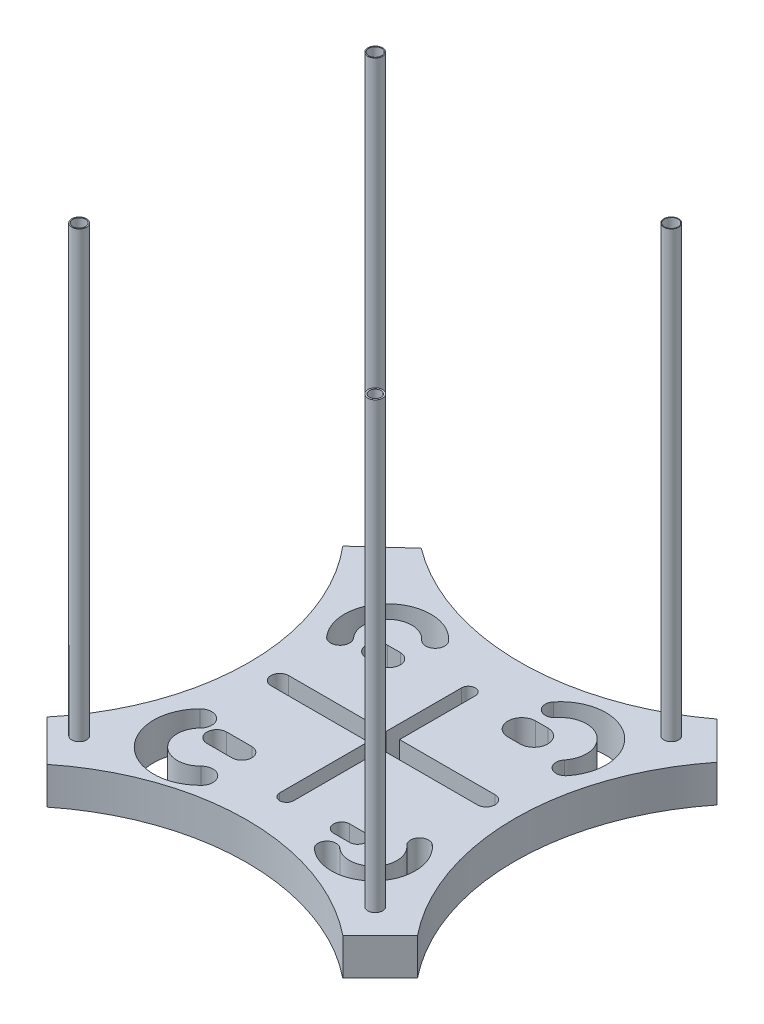
from build123d import *

# Parameters (mm, degrees)
BOSS_EXTRUDE1_DEPTH = 5
CUT_EXTRUDE1_DEPTH  = 15
CUT_EXTRUDE4_DEPTH  = 15
SKETCH7_R           = 1
BOSS_EXTRUDE2_DEPTH = 60
SKETCH8_R           = 0.873363885
CUT_EXTRUDE5_DEPTH  = 15
SKETCH9_R           = 0.918957051
CUT_EXTRUDE6_DEPTH  = 15
SKETCH10_R          = 0.859226697
CUT_EXTRUDE7_DEPTH  = 15
SKETCH11_R          = 0.786945752
CUT_EXTRUDE8_DEPTH  = 15


with BuildPart() as part:
    # Sketch1 → Boss-Extrude1 (new body)
    with BuildSketch(Plane(origin=(0, 0, 0), x_dir=(1, 0, 0), z_dir=(0, 1, 0))):
        with BuildLine():
            Line((-35.448928743, 52.732943935), (-27.948927155, 60.232942347))
            ThreePointArc((-27.948927155, 60.232942347), (-7.948927155, 52.732942347), (12.051072845, 60.232942347))
            Line((12.051072845, 60.232942347), (19.551072845, 52.732939171))
            ThreePointArc((19.551072845, 52.732939171), (12.051076647, 32.732945116), (19.551072845, 12.73295106))
            Line((19.551072845, 12.73295106), (12.051060957, 5.232942347))
            ThreePointArc((12.051060957, 5.232942347), (5.043506988, 9.818456658), (-2.948938922, 12.319169055))
            ThreePointArc((-2.948938922, 12.319169055), (-7.948938922, 12.848178709), (-12.948938922, 12.319169055))
            ThreePointArc((-12.948938922, 12.319169055), (-20.941384832, 9.818456658), (-27.9489388, 5.232942347))
            Line((-27.9489388, 5.232942347), (-35.448937212, 12.732943935))
            ThreePointArc((-35.448937212, 12.732943935), (-27.948932978, 32.732942347), (-35.448928743, 52.732943935))
        make_face()
    extrude(amount=BOSS_EXTRUDE1_DEPTH)

    # Sketch3 → Cut-Extrude1 (cut)
    with BuildSketch(Plane(origin=(0, 5, 0), x_dir=(1, 0, 0), z_dir=(0, 1, 0))):
        with BuildLine():
            Line((-27.948927155, 60.232942347), (-35.448928743, 52.732943935))
            ThreePointArc((-35.448928743, 52.732943935), (-27.948932978, 32.732942347), (-35.448937212, 12.732943935))
            Line((-35.448937212, 12.732943935), (-27.9489388, 5.232942347))
            ThreePointArc((-27.9489388, 5.232942347), (-7.948938922, 12.848178709), (12.051060957, 5.232942347))
            Line((12.051060957, 5.232942347), (19.551072845, 12.73295106))
            ThreePointArc((19.551072845, 12.73295106), (12.051076647, 32.732945116), (19.551072845, 52.732939171))
            Line((19.551072845, 52.732939171), (12.051072845, 60.232942347))
            ThreePointArc((12.051072845, 60.232942347), (-7.948927155, 52.732942347), (-27.948927155, 60.232942347))
        make_face()
        with BuildLine():
            Line((-33.493710626, 12.732943935), (-27.9489388, 7.18817211))
            ThreePointArc((-27.9489388, 7.18817211), (-7.948938922, 14.210022681), (12.051060957, 7.18817211))
            Line((12.051060957, 7.18817211), (17.099712422, 12.236821437))
            ThreePointArc((17.099712422, 12.236821437), (10.006359282, 32.484880304), (17.099712422, 52.732939171))
            Line((17.099712422, 52.732939171), (12.051072845, 57.781578748))
            ThreePointArc((12.051072845, 57.781578748), (-7.948927155, 51.108457819), (-27.948927155, 57.781578748))
            Line((-27.948927155, 57.781578748), (-33.493710626, 52.732943935))
            ThreePointArc((-33.493710626, 52.732943935), (-26.205843846, 32.732943935), (-33.493710626, 12.732943935))
        make_face(mode=Mode.SUBTRACT)
    extrude(amount=-CUT_EXTRUDE1_DEPTH, mode=Mode.SUBTRACT)


with BuildPart() as cut_extrude1_kept_piece:
    # of the separate pieces the step leaves, the one the design keeps (cut_extrude1_pieces_kept)
    add(part.part.solids().sort_by_distance((-27.9489388, 0, -7.18817211))[0])

    # Sketch4 → Cut-Extrude4 (cut)
    with BuildSketch(Plane(origin=(0, 5, 0), x_dir=(1, 0, 0), z_dir=(0, 1, 0))):
        with BuildLine():
            Line((-19.583778872, 20.459711597), (-16.194704715, 20.459711597))
            ThreePointArc((-16.194704715, 20.459711597), (-14.85807522, 21.796341092), (-16.194704715, 23.132970587))
            Line((-16.194704715, 23.132970587), (-19.583778872, 23.132970587))
            ThreePointArc((-19.583778872, 23.132970587), (-20.920408367, 21.796341092), (-19.583778872, 20.459711597))
        make_face()
        with BuildLine():
            ThreePointArc((-21.831761669, 21.796341092), (-21.78134565, 17.350791516), (-17.335796074, 17.401207535))
            ThreePointArc((-17.335796074, 17.401207535), (-15.079204869, 17.426799049), (-15.053613355, 15.170207843))
            ThreePointArc((-15.053613355, 15.170207843), (-24.012345341, 15.068608797), (-24.113944388, 24.027340783))
            ThreePointArc((-24.113944388, 24.027340783), (-21.857353183, 24.052932297), (-21.831761669, 21.796341092))
        make_face()
        with BuildLine():
            ThreePointArc((-17.153953535, 47.057082623), (-21.758601657, 47.312085175), (-22.013604209, 42.707437053))
            ThreePointArc((-22.013604209, 42.707437053), (-22.114274365, 40.88960957), (-23.932101848, 40.990279726))
            ThreePointArc((-23.932101848, 40.990279726), (-23.475758984, 49.230582815), (-15.235455895, 48.77423995))
            ThreePointArc((-15.235455895, 48.77423995), (-15.336126051, 46.956412467), (-17.153953535, 47.057082623))
        make_face()
        with BuildLine():
            ThreePointArc((-18.867938752, 44.161713483), (-20.322215182, 42.707437053), (-18.867938752, 41.253160623))
            Line((-18.867938752, 41.253160623), (-17.153953535, 41.253160623))
            ThreePointArc((-17.153953535, 41.253160623), (-15.699677105, 42.707437053), (-17.153953535, 44.161713483))
            Line((-17.153953535, 44.161713483), (-18.867938752, 44.161713483))
        make_face()
        with BuildLine():
            Line((-8.881617516, 44.161713483), (-8.881617516, 19.598774313))
            ThreePointArc((-8.881617516, 19.598774313), (-7.948927155, 18.666083952), (-7.016236793, 19.598774313))
            Line((-7.016236793, 19.598774313), (-7.016236793, 44.161713483))
            ThreePointArc((-7.016236793, 44.161713483), (-7.948927155, 45.094403844), (-8.881617516, 44.161713483))
        make_face()
        with BuildLine():
            Line((-22.013604209, 33.925546285), (5.888104042, 33.925546285))
            ThreePointArc((5.888104042, 33.925546285), (7.080706392, 32.732943935), (5.888104042, 31.540341586))
            Line((5.888104042, 31.540341586), (-22.013604209, 31.540341586))
            ThreePointArc((-22.013604209, 31.540341586), (-23.206206558, 32.732943935), (-22.013604209, 33.925546285))
        make_face()
        with BuildLine():
            ThreePointArc((6.501599793, 42.67386899), (5.971735558, 47.620514921), (1.025089628, 47.090650686))
            ThreePointArc((1.025089628, 47.090650686), (-0.822878242, 46.892704018), (-1.02082491, 48.740671887))
            ThreePointArc((-1.02082491, 48.740671887), (7.621756759, 49.666429458), (8.54751433, 41.023847789))
            ThreePointArc((8.54751433, 41.023847789), (6.699546461, 40.825901121), (6.501599793, 42.67386899))
        make_face()
        with BuildLine():
            ThreePointArc((1.638585378, 41.548852695), (3.515318655, 43.425585972), (1.638585378, 45.302319249))
            Line((1.638585378, 45.302319249), (0.002132359, 45.302319249))
            ThreePointArc((0.002132359, 45.302319249), (-1.874600919, 43.425585972), (0.002132359, 41.548852695))
            Line((0.002132359, 41.548852695), (1.638585378, 41.548852695))
        make_face()
        with BuildLine():
            ThreePointArc((7.510988879, 23.827432924), (5.783954474, 23.723283356), (5.888104042, 21.996248951))
            ThreePointArc((5.888104042, 21.996248951), (6.160819348, 17.474014981), (1.638585378, 17.201299676))
            ThreePointArc((1.638585378, 17.201299676), (-0.088449027, 17.097150108), (0.015700541, 15.370115703))
            ThreePointArc((0.015700541, 15.370115703), (7.992003321, 15.851130144), (7.510988879, 23.827432924))
        make_face()
        with BuildLine():
            ThreePointArc((1.638585378, 18.510682614), (2.726677077, 19.598774313), (1.638585378, 20.686866012))
            Line((1.638585378, 20.686866012), (-0.516238104, 20.686866012))
            ThreePointArc((-0.516238104, 20.686866012), (-1.604329803, 19.598774313), (-0.516238104, 18.510682614))
            Line((-0.516238104, 18.510682614), (1.638585378, 18.510682614))
        make_face()
    extrude(amount=-CUT_EXTRUDE4_DEPTH, mode=Mode.SUBTRACT)

    # Sketch7 → Boss-Extrude2 (add)
    with BuildSketch(Plane(origin=(0, 5, 0), x_dir=(1, 0, 0), z_dir=(0, 1, 0))):
        with Locations(Location((-29.113038054, 52.732942347, 0), (0, 0, 270))):
            Circle(SKETCH7_R)
        with Locations(Location((10.886963534, 52.732942347, 0), (0, 0, 270))):
            Circle(SKETCH7_R)
        with Locations(Location((10.886963534, 12.732942347, 0), (0, 0, 270))):
            Circle(SKETCH7_R)
        with Locations(Location((-29.113046524, 12.732942347, 0), (0, 0, 270))):
            Circle(SKETCH7_R)
    extrude(amount=BOSS_EXTRUDE2_DEPTH)

    # Sketch8 → Cut-Extrude5 (cut)
    with BuildSketch(Plane(origin=(0, 65, 0), x_dir=(1, 0, 0), z_dir=(0, 1, 0))):
        with Locations(Location((-29.113038054, 52.732942347, 0), (0, 0, 270))):
            Circle(SKETCH8_R)
    extrude(amount=-CUT_EXTRUDE5_DEPTH, mode=Mode.SUBTRACT)

    # Sketch9 → Cut-Extrude6 (cut)
    with BuildSketch(Plane(origin=(0, 65, 0), x_dir=(1, 0, 0), z_dir=(0, 1, 0))):
        with Locations(Location((10.886963534, 52.732942347, 0), (0, 0, 270))):
            Circle(SKETCH9_R)
    extrude(amount=-CUT_EXTRUDE6_DEPTH, mode=Mode.SUBTRACT)

    # Sketch10 → Cut-Extrude7 (cut)
    with BuildSketch(Plane(origin=(0, 65, 0), x_dir=(1, 0, 0), z_dir=(0, 1, 0))):
        with Locations(Location((-29.113046524, 12.732942347, 0), (0, 0, 270))):
            Circle(SKETCH10_R)
    extrude(amount=-CUT_EXTRUDE7_DEPTH, mode=Mode.SUBTRACT)

    # Sketch11 → Cut-Extrude8 (cut)
    with BuildSketch(Plane(origin=(0, 65, 0), x_dir=(1, 0, 0), z_dir=(0, 1, 0))):
        with Locations(Location((10.886963534, 12.732942347, 0), (0, 0, 270))):
            Circle(SKETCH11_R)
    extrude(amount=-CUT_EXTRUDE8_DEPTH, mode=Mode.SUBTRACT)


solid = cut_extrude1_kept_piece.part
